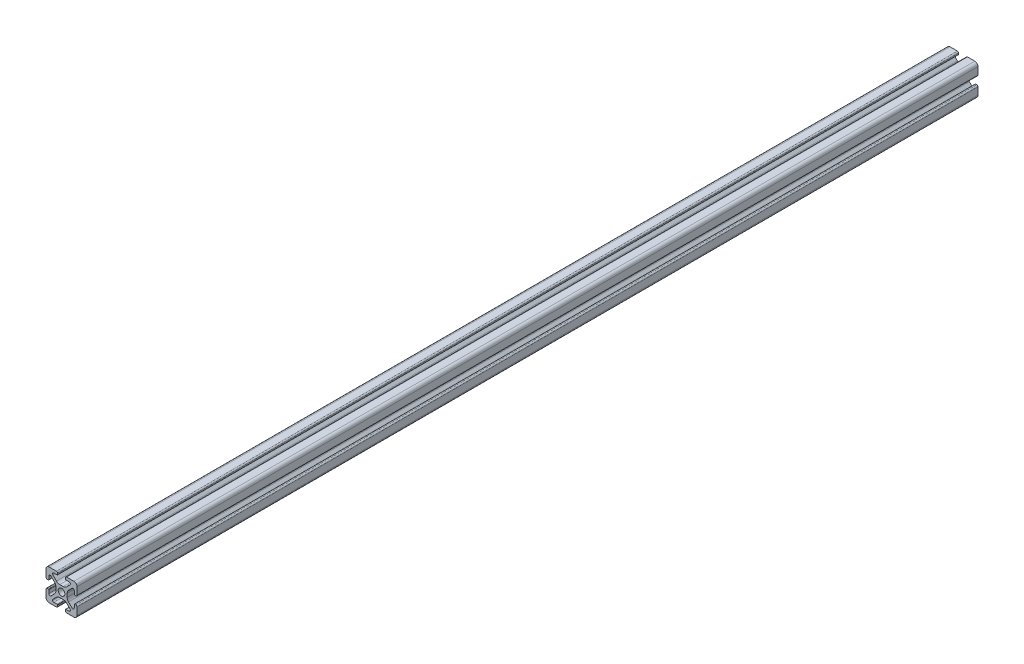
from build123d import *

# Parameters (mm, degrees)
SKETCH1_R           = 2.1463
BOSS_EXTRUDE1_DEPTH = 290


with BuildPart() as part:
    # Sketch1 → Boss-Extrude1 (new body, symmetric)
    with BuildSketch(Plane.XY):
        with BuildLine():
            Line((-9.9949, 7.9883), (-9.9949, 3.2893))
            ThreePointArc((-9.9949, 3.2893), (-9.76427588, 2.73252412), (-9.2075, 2.5019))
            Line((-9.2075, 2.5019), (-8.4963, 2.5019))
            ThreePointArc((-8.4963, 2.5019), (-8.280773853, 2.591173853), (-8.1915, 2.8067))
            Line((-8.1915, 2.8067), (-8.1915, 4.9149))
            ThreePointArc((-8.1915, 4.9149), (-7.674065253, 5.689295824), (-6.760603096, 5.507596904))
            Line((-6.760603096, 5.507596904), (-4.505765747, 3.252759555))
            ThreePointArc((-4.505765747, 3.252759555), (-3.856054457, 2.280397894), (-3.627906192, 1.133419111))
            Line((-3.627906192, 1.133419111), (-3.627906192, -1.133419111))
            ThreePointArc((-3.627906192, -1.133419111), (-3.856054457, -2.280397894), (-4.505765747, -3.252759555))
            Line((-4.505765747, -3.252759555), (-6.760603096, -5.507596904))
            ThreePointArc((-6.760603096, -5.507596904), (-7.674065253, -5.689295824), (-8.1915, -4.9149))
            Line((-8.1915, -4.9149), (-8.1915, -2.8067))
            ThreePointArc((-8.1915, -2.8067), (-8.280773853, -2.591173853), (-8.4963, -2.5019))
            Line((-8.4963, -2.5019), (-9.2075, -2.5019))
            ThreePointArc((-9.2075, -2.5019), (-9.76427588, -2.73252412), (-9.9949, -3.2893))
            Line((-9.9949, -3.2893), (-9.9949, -7.9883))
            ThreePointArc((-9.9949, -7.9883), (-9.407180467, -9.407180467), (-7.9883, -9.9949))
            Line((-7.9883, -9.9949), (-3.2893, -9.9949))
            ThreePointArc((-3.2893, -9.9949), (-2.73252412, -9.76427588), (-2.5019, -9.2075))
            Line((-2.5019, -9.2075), (-2.5019, -8.4963))
            ThreePointArc((-2.5019, -8.4963), (-2.591173853, -8.280773853), (-2.8067, -8.1915))
            Line((-2.8067, -8.1915), (-4.9149, -8.1915))
            ThreePointArc((-4.9149, -8.1915), (-5.689295824, -7.674065253), (-5.507596904, -6.760603096))
            Line((-5.507596904, -6.760603096), (-3.252759555, -4.505765747))
            ThreePointArc((-3.252759555, -4.505765747), (-2.280397894, -3.856054457), (-1.133419111, -3.627906192))
            Line((-1.133419111, -3.627906192), (1.133419111, -3.627906192))
            ThreePointArc((1.133419111, -3.627906192), (2.280397894, -3.856054457), (3.252759555, -4.505765747))
            Line((3.252759555, -4.505765747), (5.507596904, -6.760603096))
            ThreePointArc((5.507596904, -6.760603096), (5.689295824, -7.674065253), (4.9149, -8.1915))
            Line((4.9149, -8.1915), (2.8067, -8.1915))
            ThreePointArc((2.8067, -8.1915), (2.591173853, -8.280773853), (2.5019, -8.4963))
            Line((2.5019, -8.4963), (2.5019, -9.2075))
            ThreePointArc((2.5019, -9.2075), (2.73252412, -9.76427588), (3.2893, -9.9949))
            Line((3.2893, -9.9949), (7.9883, -9.9949))
            ThreePointArc((7.9883, -9.9949), (9.407180467, -9.407180467), (9.9949, -7.9883))
            Line((9.9949, -7.9883), (9.9949, -3.2893))
            ThreePointArc((9.9949, -3.2893), (9.76427588, -2.73252412), (9.2075, -2.5019))
            Line((9.2075, -2.5019), (8.4963, -2.5019))
            ThreePointArc((8.4963, -2.5019), (8.280773853, -2.591173853), (8.1915, -2.8067))
            Line((8.1915, -2.8067), (8.1915, -4.9149))
            ThreePointArc((8.1915, -4.9149), (7.674065253, -5.689295824), (6.760603096, -5.507596904))
            Line((6.760603096, -5.507596904), (4.505765747, -3.252759555))
            ThreePointArc((4.505765747, -3.252759555), (3.856054457, -2.280397894), (3.627906192, -1.133419111))
            Line((3.627906192, -1.133419111), (3.627906192, 1.133419111))
            ThreePointArc((3.627906192, 1.133419111), (3.856054457, 2.280397894), (4.505765747, 3.252759555))
            Line((4.505765747, 3.252759555), (6.760603096, 5.507596904))
            ThreePointArc((6.760603096, 5.507596904), (7.674065253, 5.689295824), (8.1915, 4.9149))
            Line((8.1915, 4.9149), (8.1915, 2.8067))
            ThreePointArc((8.1915, 2.8067), (8.280773853, 2.591173853), (8.4963, 2.5019))
            Line((8.4963, 2.5019), (9.2075, 2.5019))
            ThreePointArc((9.2075, 2.5019), (9.76427588, 2.73252412), (9.9949, 3.2893))
            Line((9.9949, 3.2893), (9.9949, 7.9883))
            ThreePointArc((9.9949, 7.9883), (9.407180467, 9.407180467), (7.9883, 9.9949))
            Line((7.9883, 9.9949), (3.2893, 9.9949))
            ThreePointArc((3.2893, 9.9949), (2.73252412, 9.76427588), (2.5019, 9.2075))
            Line((2.5019, 9.2075), (2.5019, 8.4963))
            ThreePointArc((2.5019, 8.4963), (2.591173853, 8.280773853), (2.8067, 8.1915))
            Line((2.8067, 8.1915), (4.9149, 8.1915))
            ThreePointArc((4.9149, 8.1915), (5.689295824, 7.674065253), (5.507596904, 6.760603096))
            Line((5.507596904, 6.760603096), (3.252759555, 4.505765747))
            ThreePointArc((3.252759555, 4.505765747), (2.280397894, 3.856054457), (1.133419111, 3.627906192))
            Line((1.133419111, 3.627906192), (-1.133419111, 3.627906192))
            ThreePointArc((-1.133419111, 3.627906192), (-2.280397894, 3.856054457), (-3.252759555, 4.505765747))
            Line((-3.252759555, 4.505765747), (-5.507596904, 6.760603096))
            ThreePointArc((-5.507596904, 6.760603096), (-5.689295824, 7.674065253), (-4.9149, 8.1915))
            Line((-4.9149, 8.1915), (-2.8067, 8.1915))
            ThreePointArc((-2.8067, 8.1915), (-2.591173853, 8.280773853), (-2.5019, 8.4963))
            Line((-2.5019, 8.4963), (-2.5019, 9.2075))
            ThreePointArc((-2.5019, 9.2075), (-2.73252412, 9.76427588), (-3.2893, 9.9949))
            Line((-3.2893, 9.9949), (-7.9883, 9.9949))
            ThreePointArc((-7.9883, 9.9949), (-9.407180467, 9.407180467), (-9.9949, 7.9883))
        make_face()
        Circle(SKETCH1_R, mode=Mode.SUBTRACT)
    extrude(amount=BOSS_EXTRUDE1_DEPTH, both=True)


solid = part.part
